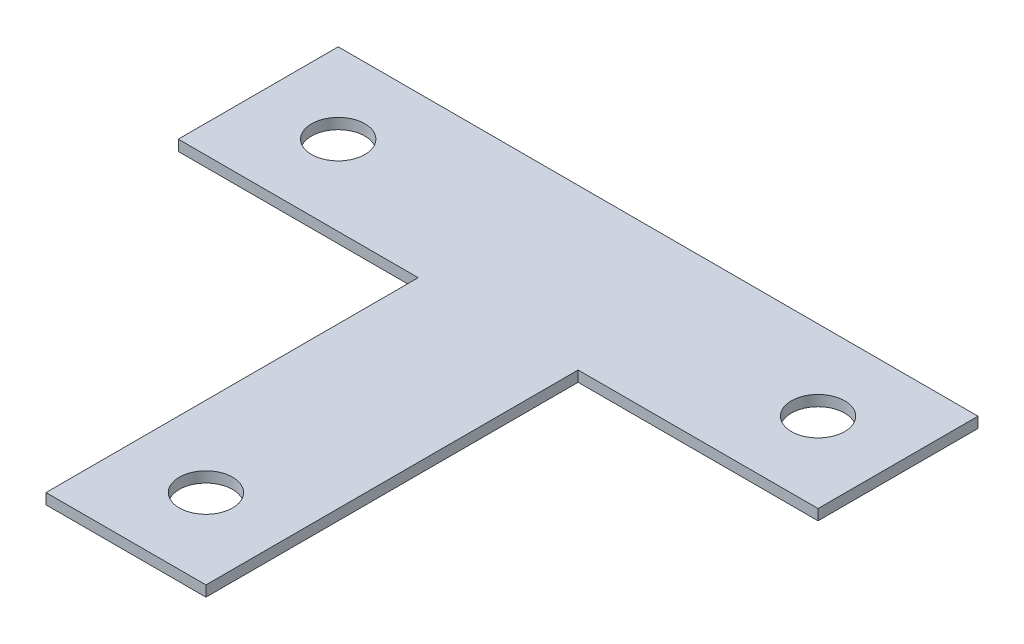
from build123d import *

# Parameters (mm, degrees)
SKETCH1_R           = 6.35
BOSS_EXTRUDE1_DEPTH = 2.54


with BuildPart() as part:
    # Sketch1 → Boss-Extrude1 (new body)
    with BuildSketch(Plane(origin=(0, 0, 0), x_dir=(1, 0, 0), z_dir=(0, 1, 0))):
        Polygon((-76.2, 25.158094898), (-19.05, 25.158094898), (-19.05, -63.5), (19.05, -63.5), (19.05, 25.158094898), (76.2, 25.158094898), (76.2, 63.258094898), (-76.2, 63.258094898), align=None)
        with Locations((0, -44.45)):
            Circle(SKETCH1_R, mode=Mode.SUBTRACT)
        with Locations((-57.15, 44.208094898)):
            Circle(SKETCH1_R, mode=Mode.SUBTRACT)
        with Locations((57.15, 44.208094898)):
            Circle(SKETCH1_R, mode=Mode.SUBTRACT)
    extrude(amount=BOSS_EXTRUDE1_DEPTH)


solid = part.part
